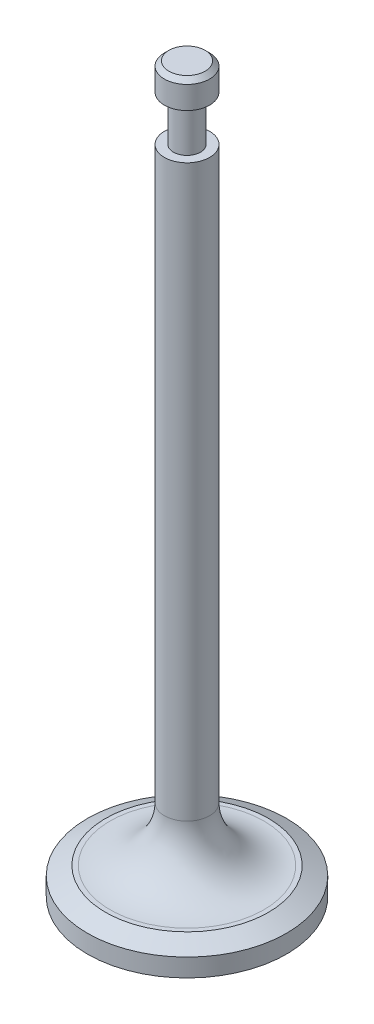
from build123d import *

# Parameters (mm, degrees)
FILLET2_R      = 6
CHAMFER1_SIZE  = 1
CHAMFER1_SIZE2 = 2
CHAMFER2_SIZE  = 0.5


with BuildPart() as part:
    # Sketch1 → Revolve1 (revolve)
    with BuildSketch(Plane(origin=(0, 0, 0), x_dir=(0, 0, -1), z_dir=(1, 0, 0))):
        Polygon((0, 0), (0, -80), (11, -80), (11, -77), (2.5, -77), (2.5, -8), (1.5, -8), (1.5, -3), (2.5, -3), (2.5, 0), align=None)
    revolve(axis=Axis((0, 0, 0), (0, -1, 0)))

    # Fillet2
    fillet2_edges = [part.edges().sort_by_distance(p)[0] for p in [
        (0, -77, 2.5),
    ]]
    fillet(fillet2_edges, radius=FILLET2_R)

    # Chamfer1
    chamfer1_edges = [part.edges().sort_by_distance(p)[0] for p in [
        (0, -77, 11),
    ]]
    chamfer1_side = [part.faces().sort_by_distance(p)[0] for p in [
        (0, -78.5, 11),
    ]]
    chamfer(chamfer1_edges, length=CHAMFER1_SIZE, length2=CHAMFER1_SIZE2, reference=chamfer1_side[0])

    # Chamfer2
    chamfer2_edges = [part.edges().sort_by_distance(p)[0] for p in [
        (0, 0, 2.5),
    ]]
    chamfer(chamfer2_edges, length=CHAMFER2_SIZE)


solid = part.part
